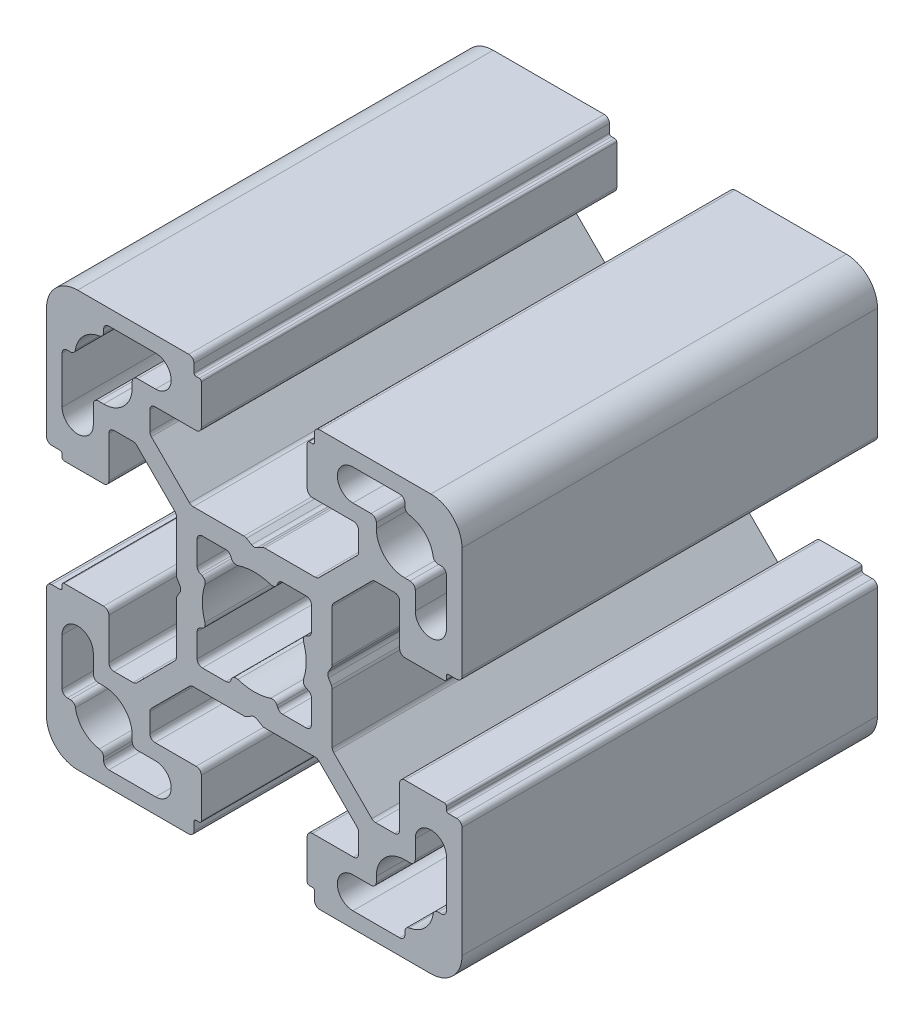
from build123d import *

# Parameters (mm, degrees)
EXTRUDE_1_DEPTH = 40


with BuildPart() as part:
    # Эскиз1 → Бобышка-Вытянуть1 (new body)
    with BuildSketch(Plane.XY):
        with BuildLine():
            Line((-18.5, -5.6), (-18.5, -5.3))
            ThreePointArc((-18.5, -5.3), (-18.441421356, -5.158578644), (-18.3, -5.1))
            Line((-18.3, -5.1), (-14.5, -5.1))
            ThreePointArc((-14.5, -5.1), (-14.146446609, -5.246446609), (-14, -5.6))
            Line((-14, -5.6), (-14, -9.55))
            ThreePointArc((-14, -9.55), (-13.853553391, -9.903553391), (-13.5, -10.05))
            Line((-13.5, -10.05), (-11.671320344, -10.05))
            ThreePointArc((-11.671320344, -10.05), (-11.479978627, -10.011939766), (-11.317766953, -9.903553391))
            Line((-11.317766953, -9.903553391), (-7.646446609, -6.232233047))
            ThreePointArc((-7.646446609, -6.232233047), (-7.538060234, -6.070021373), (-7.5, -5.878679656))
            Line((-7.5, -5.878679656), (-7.5, -1))
            ThreePointArc((-7.5, -1), (-7.482962913, -0.870590477), (-7.433012702, -0.75))
            Line((-7.433012702, -0.75), (-7.144337567, -0.25))
            ThreePointArc((-7.144337567, -0.25), (-7.077350269, 0), (-7.144337567, 0.25))
            Line((-7.144337567, 0.25), (-7.433012702, 0.75))
            ThreePointArc((-7.433012702, 0.75), (-7.482962913, 0.870590477), (-7.5, 1))
            Line((-7.5, 1), (-7.5, 5.878679656))
            ThreePointArc((-7.5, 5.878679656), (-7.538060234, 6.070021373), (-7.646446609, 6.232233047))
            Line((-7.646446609, 6.232233047), (-11.317766953, 9.903553391))
            ThreePointArc((-11.317766953, 9.903553391), (-11.479978627, 10.011939766), (-11.671320344, 10.05))
            Line((-11.671320344, 10.05), (-13.5, 10.05))
            ThreePointArc((-13.5, 10.05), (-13.853553391, 9.903553391), (-14, 9.55))
            Line((-14, 9.55), (-14, 5.6))
            ThreePointArc((-14, 5.6), (-14.146446609, 5.246446609), (-14.5, 5.1))
            Line((-14.5, 5.1), (-18.3, 5.1))
            ThreePointArc((-18.3, 5.1), (-18.441421356, 5.158578644), (-18.5, 5.3))
            Line((-18.5, 5.3), (-18.5, 5.6))
            ThreePointArc((-18.5, 5.6), (-18.558578644, 5.741421356), (-18.7, 5.8))
            Line((-18.7, 5.8), (-19.5, 5.8))
            ThreePointArc((-19.5, 5.8), (-19.853553391, 5.946446609), (-20, 6.3))
            Line((-20, 6.3), (-20, 17))
            ThreePointArc((-20, 17), (-19.121320344, 19.121320344), (-17, 20))
            Line((-17, 20), (-6.3, 20))
            ThreePointArc((-6.3, 20), (-5.946446609, 19.853553391), (-5.8, 19.5))
            Line((-5.8, 19.5), (-5.8, 18.7))
            ThreePointArc((-5.8, 18.7), (-5.741421356, 18.558578644), (-5.6, 18.5))
            Line((-5.6, 18.5), (-5.3, 18.5))
            ThreePointArc((-5.3, 18.5), (-5.158578644, 18.441421356), (-5.1, 18.3))
            Line((-5.1, 18.3), (-5.1, 14.5))
            ThreePointArc((-5.1, 14.5), (-5.246446609, 14.146446609), (-5.6, 14))
            Line((-5.6, 14), (-9.55, 14))
            ThreePointArc((-9.55, 14), (-9.903553391, 13.853553391), (-10.05, 13.5))
            Line((-10.05, 13.5), (-10.05, 11.671320344))
            ThreePointArc((-10.05, 11.671320344), (-10.011939766, 11.479978627), (-9.903553391, 11.317766953))
            Line((-9.903553391, 11.317766953), (-6.232233047, 7.646446609))
            ThreePointArc((-6.232233047, 7.646446609), (-6.070021373, 7.538060234), (-5.878679656, 7.5))
            Line((-5.878679656, 7.5), (-1, 7.5))
            ThreePointArc((-1, 7.5), (-0.870590477, 7.482962913), (-0.75, 7.433012702))
            Line((-0.75, 7.433012702), (-0.25, 7.144337567))
            ThreePointArc((-0.25, 7.144337567), (0, 7.077350269), (0.25, 7.144337567))
            Line((0.25, 7.144337567), (0.75, 7.433012702))
            ThreePointArc((0.75, 7.433012702), (0.870590477, 7.482962913), (1, 7.5))
            Line((1, 7.5), (5.878679656, 7.5))
            ThreePointArc((5.878679656, 7.5), (6.070021373, 7.538060234), (6.232233047, 7.646446609))
            Line((6.232233047, 7.646446609), (9.903553391, 11.317766953))
            ThreePointArc((9.903553391, 11.317766953), (10.011939766, 11.479978627), (10.05, 11.671320344))
            Line((10.05, 11.671320344), (10.05, 13.5))
            ThreePointArc((10.05, 13.5), (9.903553391, 13.853553391), (9.55, 14))
            Line((9.55, 14), (5.6, 14))
            ThreePointArc((5.6, 14), (5.246446609, 14.146446609), (5.1, 14.5))
            Line((5.1, 14.5), (5.1, 18.3))
            ThreePointArc((5.1, 18.3), (5.158578644, 18.441421356), (5.3, 18.5))
            Line((5.3, 18.5), (5.6, 18.5))
            ThreePointArc((5.6, 18.5), (5.741421356, 18.558578644), (5.8, 18.7))
            Line((5.8, 18.7), (5.8, 19.5))
            ThreePointArc((5.8, 19.5), (5.946446609, 19.853553391), (6.3, 20))
            Line((6.3, 20), (17, 20))
            ThreePointArc((17, 20), (19.121320344, 19.121320344), (20, 17))
            Line((20, 17), (20, 6.3))
            ThreePointArc((20, 6.3), (19.853553391, 5.946446609), (19.5, 5.8))
            Line((19.5, 5.8), (18.7, 5.8))
            ThreePointArc((18.7, 5.8), (18.558578644, 5.741421356), (18.5, 5.6))
            Line((18.5, 5.6), (18.5, 5.3))
            ThreePointArc((18.5, 5.3), (18.441421356, 5.158578644), (18.3, 5.1))
            Line((18.3, 5.1), (14.5, 5.1))
            ThreePointArc((14.5, 5.1), (14.146446609, 5.246446609), (14, 5.6))
            Line((14, 5.6), (14, 9.55))
            ThreePointArc((14, 9.55), (13.853553391, 9.903553391), (13.5, 10.05))
            Line((13.5, 10.05), (11.671320344, 10.05))
            ThreePointArc((11.671320344, 10.05), (11.479978627, 10.011939766), (11.317766953, 9.903553391))
            Line((11.317766953, 9.903553391), (7.646446609, 6.232233047))
            ThreePointArc((7.646446609, 6.232233047), (7.538060234, 6.070021373), (7.5, 5.878679656))
            Line((7.5, 5.878679656), (7.5, 1))
            ThreePointArc((7.5, 1), (7.482962913, 0.870590477), (7.433012702, 0.75))
            Line((7.433012702, 0.75), (7.144337567, 0.25))
            ThreePointArc((7.144337567, 0.25), (7.077350269, 0), (7.144337567, -0.25))
            Line((7.144337567, -0.25), (7.433012702, -0.75))
            ThreePointArc((7.433012702, -0.75), (7.482962913, -0.870590477), (7.5, -1))
            Line((7.5, -1), (7.5, -5.878679656))
            ThreePointArc((7.5, -5.878679656), (7.538060234, -6.070021373), (7.646446609, -6.232233047))
            Line((7.646446609, -6.232233047), (11.317766953, -9.903553391))
            ThreePointArc((11.317766953, -9.903553391), (11.479978627, -10.011939766), (11.671320344, -10.05))
            Line((11.671320344, -10.05), (13.5, -10.05))
            ThreePointArc((13.5, -10.05), (13.853553391, -9.903553391), (14, -9.55))
            Line((14, -9.55), (14, -5.6))
            ThreePointArc((14, -5.6), (14.146446609, -5.246446609), (14.5, -5.1))
            Line((14.5, -5.1), (18.3, -5.1))
            ThreePointArc((18.3, -5.1), (18.441421356, -5.158578644), (18.5, -5.3))
            Line((18.5, -5.3), (18.5, -5.6))
            ThreePointArc((18.5, -5.6), (18.558578644, -5.741421356), (18.7, -5.8))
            Line((18.7, -5.8), (19.5, -5.8))
            ThreePointArc((19.5, -5.8), (19.853553391, -5.946446609), (20, -6.3))
            Line((20, -6.3), (20, -17))
            ThreePointArc((20, -17), (19.121320344, -19.121320344), (17, -20))
            Line((17, -20), (6.3, -20))
            ThreePointArc((6.3, -20), (5.946446609, -19.853553391), (5.8, -19.5))
            Line((5.8, -19.5), (5.8, -18.7))
            ThreePointArc((5.8, -18.7), (5.741421356, -18.558578644), (5.6, -18.5))
            Line((5.6, -18.5), (5.3, -18.5))
            ThreePointArc((5.3, -18.5), (5.158578644, -18.441421356), (5.1, -18.3))
            Line((5.1, -18.3), (5.1, -14.5))
            ThreePointArc((5.1, -14.5), (5.246446609, -14.146446609), (5.6, -14))
            Line((5.6, -14), (9.55, -14))
            ThreePointArc((9.55, -14), (9.903553391, -13.853553391), (10.05, -13.5))
            Line((10.05, -13.5), (10.05, -11.671320344))
            ThreePointArc((10.05, -11.671320344), (10.011939766, -11.479978627), (9.903553391, -11.317766953))
            Line((9.903553391, -11.317766953), (6.232233047, -7.646446609))
            ThreePointArc((6.232233047, -7.646446609), (6.070021373, -7.538060234), (5.878679656, -7.5))
            Line((5.878679656, -7.5), (1, -7.5))
            ThreePointArc((1, -7.5), (0.870590477, -7.482962913), (0.75, -7.433012702))
            Line((0.75, -7.433012702), (0.25, -7.144337567))
            ThreePointArc((0.25, -7.144337567), (0, -7.077350269), (-0.25, -7.144337567))
            Line((-0.25, -7.144337567), (-0.75, -7.433012702))
            ThreePointArc((-0.75, -7.433012702), (-0.870590477, -7.482962913), (-1, -7.5))
            Line((-1, -7.5), (-5.878679656, -7.5))
            ThreePointArc((-5.878679656, -7.5), (-6.070021373, -7.538060234), (-6.232233047, -7.646446609))
            Line((-6.232233047, -7.646446609), (-9.903553391, -11.317766953))
            ThreePointArc((-9.903553391, -11.317766953), (-10.011939766, -11.479978627), (-10.05, -11.671320344))
            Line((-10.05, -11.671320344), (-10.05, -13.5))
            ThreePointArc((-10.05, -13.5), (-9.903553391, -13.853553391), (-9.55, -14))
            Line((-9.55, -14), (-5.6, -14))
            ThreePointArc((-5.6, -14), (-5.246446609, -14.146446609), (-5.1, -14.5))
            Line((-5.1, -14.5), (-5.1, -18.3))
            ThreePointArc((-5.1, -18.3), (-5.158578644, -18.441421356), (-5.3, -18.5))
            Line((-5.3, -18.5), (-5.6, -18.5))
            ThreePointArc((-5.6, -18.5), (-5.741421356, -18.558578644), (-5.8, -18.7))
            Line((-5.8, -18.7), (-5.8, -19.5))
            ThreePointArc((-5.8, -19.5), (-5.946446609, -19.853553391), (-6.3, -20))
            Line((-6.3, -20), (-17, -20))
            ThreePointArc((-17, -20), (-19.121320344, -19.121320344), (-20, -17))
            Line((-20, -17), (-20, -6.3))
            ThreePointArc((-20, -6.3), (-19.853553391, -5.946446609), (-19.5, -5.8))
            Line((-19.5, -5.8), (-18.7, -5.8))
            ThreePointArc((-18.7, -5.8), (-18.558578644, -5.741421356), (-18.5, -5.6))
        make_face()
        with BuildLine():
            Line((-14.5, 18), (-14.5, 17.711308145))
            ThreePointArc((-14.5, 17.711308145), (-14.620222737, 17.386086327), (-14.923076923, 17.217260738))
            ThreePointArc((-14.923076923, 17.217260738), (-16.444543648, 16.444543648), (-17.217260738, 14.923076923))
            ThreePointArc((-17.217260738, 14.923076923), (-17.386086327, 14.620222737), (-17.711308145, 14.5))
            Line((-17.711308145, 14.5), (-18, 14.5))
            ThreePointArc((-18, 14.5), (-18.353553391, 14.353553391), (-18.5, 14))
            Line((-18.5, 14), (-18.5, 9.5))
            ThreePointArc((-18.5, 9.5), (-17, 8), (-15.5, 9.5))
            Line((-15.5, 9.5), (-15.5, 11.25))
            ThreePointArc((-15.5, 11.25), (-15.353553391, 11.603553391), (-15, 11.75))
            Line((-15, 11.75), (-14.5, 11.75))
            ThreePointArc((-14.5, 11.75), (-12.555456352, 12.555456352), (-11.75, 14.5))
            Line((-11.75, 14.5), (-11.75, 15))
            ThreePointArc((-11.75, 15), (-11.603553391, 15.353553391), (-11.25, 15.5))
            Line((-11.25, 15.5), (-9.5, 15.5))
            ThreePointArc((-9.5, 15.5), (-8, 17), (-9.5, 18.5))
            Line((-9.5, 18.5), (-14, 18.5))
            ThreePointArc((-14, 18.5), (-14.353553391, 18.353553391), (-14.5, 18))
        make_face(mode=Mode.SUBTRACT)
        with BuildLine():
            Line((-5.199374534, 2.269284327), (-5.020474811, 2.191496514))
            ThreePointArc((-5.020474811, 2.191496514), (-4.763314859, 1.936869058), (-4.745317587, 1.57542407))
            ThreePointArc((-4.745317587, 1.57542407), (-5, 0), (-4.745317587, -1.57542407))
            ThreePointArc((-4.745317587, -1.57542407), (-4.763314859, -1.936869058), (-5.020474811, -2.191496514))
            Line((-5.020474811, -2.191496514), (-5.199374534, -2.269284327))
            ThreePointArc((-5.199374534, -2.269284327), (-5.418143078, -2.45366775), (-5.5, -2.727814365))
            Line((-5.5, -2.727814365), (-5.5, -5))
            ThreePointArc((-5.5, -5), (-5.353553391, -5.353553391), (-5, -5.5))
            Line((-5, -5.5), (-2.727814365, -5.5))
            ThreePointArc((-2.727814365, -5.5), (-2.45366775, -5.418143078), (-2.269284327, -5.199374534))
            Line((-2.269284327, -5.199374534), (-2.191496514, -5.020474811))
            ThreePointArc((-2.191496514, -5.020474811), (-1.936869058, -4.763314859), (-1.57542407, -4.745317587))
            ThreePointArc((-1.57542407, -4.745317587), (0, -5), (1.57542407, -4.745317587))
            ThreePointArc((1.57542407, -4.745317587), (1.936869058, -4.763314859), (2.191496514, -5.020474811))
            Line((2.191496514, -5.020474811), (2.269284327, -5.199374534))
            ThreePointArc((2.269284327, -5.199374534), (2.45366775, -5.418143078), (2.727814365, -5.5))
            Line((2.727814365, -5.5), (5, -5.5))
            ThreePointArc((5, -5.5), (5.353553391, -5.353553391), (5.5, -5))
            Line((5.5, -5), (5.5, -2.727814365))
            ThreePointArc((5.5, -2.727814365), (5.418143078, -2.45366775), (5.199374534, -2.269284327))
            Line((5.199374534, -2.269284327), (5.020474811, -2.191496514))
            ThreePointArc((5.020474811, -2.191496514), (4.763314859, -1.936869058), (4.745317587, -1.57542407))
            ThreePointArc((4.745317587, -1.57542407), (5, 0), (4.745317587, 1.57542407))
            ThreePointArc((4.745317587, 1.57542407), (4.763314859, 1.936869058), (5.020474811, 2.191496514))
            Line((5.020474811, 2.191496514), (5.199374534, 2.269284327))
            ThreePointArc((5.199374534, 2.269284327), (5.418143078, 2.45366775), (5.5, 2.727814365))
            Line((5.5, 2.727814365), (5.5, 5))
            ThreePointArc((5.5, 5), (5.353553391, 5.353553391), (5, 5.5))
            Line((5, 5.5), (2.727814365, 5.5))
            ThreePointArc((2.727814365, 5.5), (2.45366775, 5.418143078), (2.269284327, 5.199374534))
            Line((2.269284327, 5.199374534), (2.191496514, 5.020474811))
            ThreePointArc((2.191496514, 5.020474811), (1.936869058, 4.763314859), (1.57542407, 4.745317587))
            ThreePointArc((1.57542407, 4.745317587), (0, 5), (-1.57542407, 4.745317587))
            ThreePointArc((-1.57542407, 4.745317587), (-1.936869058, 4.763314859), (-2.191496514, 5.020474811))
            Line((-2.191496514, 5.020474811), (-2.269284327, 5.199374534))
            ThreePointArc((-2.269284327, 5.199374534), (-2.45366775, 5.418143078), (-2.727814365, 5.5))
            Line((-2.727814365, 5.5), (-5, 5.5))
            ThreePointArc((-5, 5.5), (-5.353553391, 5.353553391), (-5.5, 5))
            Line((-5.5, 5), (-5.5, 2.727814365))
            ThreePointArc((-5.5, 2.727814365), (-5.418143078, 2.45366775), (-5.199374534, 2.269284327))
        make_face(mode=Mode.SUBTRACT)
        with BuildLine():
            Line((15.5, 9.5), (15.5, 11.25))
            ThreePointArc((15.5, 11.25), (15.353553391, 11.603553391), (15, 11.75))
            Line((15, 11.75), (14.5, 11.75))
            ThreePointArc((14.5, 11.75), (12.555456352, 12.555456352), (11.75, 14.5))
            Line((11.75, 14.5), (11.75, 15))
            ThreePointArc((11.75, 15), (11.603553391, 15.353553391), (11.25, 15.5))
            Line((11.25, 15.5), (9.5, 15.5))
            ThreePointArc((9.5, 15.5), (8, 17), (9.5, 18.5))
            Line((9.5, 18.5), (14, 18.5))
            ThreePointArc((14, 18.5), (14.353553391, 18.353553391), (14.5, 18))
            Line((14.5, 18), (14.5, 17.711308145))
            ThreePointArc((14.5, 17.711308145), (14.620222737, 17.386086327), (14.923076923, 17.217260738))
            ThreePointArc((14.923076923, 17.217260738), (16.444543648, 16.444543648), (17.217260738, 14.923076923))
            ThreePointArc((17.217260738, 14.923076923), (17.386086327, 14.620222737), (17.711308145, 14.5))
            Line((17.711308145, 14.5), (18, 14.5))
            ThreePointArc((18, 14.5), (18.353553391, 14.353553391), (18.5, 14))
            Line((18.5, 14), (18.5, 9.5))
            ThreePointArc((18.5, 9.5), (17, 8), (15.5, 9.5))
        make_face(mode=Mode.SUBTRACT)
        with BuildLine():
            Line((14.5, -18), (14.5, -17.711308145))
            ThreePointArc((14.5, -17.711308145), (14.620222737, -17.386086327), (14.923076923, -17.217260738))
            ThreePointArc((14.923076923, -17.217260738), (16.444543648, -16.444543648), (17.217260738, -14.923076923))
            ThreePointArc((17.217260738, -14.923076923), (17.386086327, -14.620222737), (17.711308145, -14.5))
            Line((17.711308145, -14.5), (18, -14.5))
            ThreePointArc((18, -14.5), (18.353553391, -14.353553391), (18.5, -14))
            Line((18.5, -14), (18.5, -9.5))
            ThreePointArc((18.5, -9.5), (17, -8), (15.5, -9.5))
            Line((15.5, -9.5), (15.5, -11.25))
            ThreePointArc((15.5, -11.25), (15.353553391, -11.603553391), (15, -11.75))
            Line((15, -11.75), (14.5, -11.75))
            ThreePointArc((14.5, -11.75), (12.555456352, -12.555456352), (11.75, -14.5))
            Line((11.75, -14.5), (11.75, -15))
            ThreePointArc((11.75, -15), (11.603553391, -15.353553391), (11.25, -15.5))
            Line((11.25, -15.5), (9.5, -15.5))
            ThreePointArc((9.5, -15.5), (8, -17), (9.5, -18.5))
            Line((9.5, -18.5), (14, -18.5))
            ThreePointArc((14, -18.5), (14.353553391, -18.353553391), (14.5, -18))
        make_face(mode=Mode.SUBTRACT)
        with BuildLine():
            Line((-15.5, -9.5), (-15.5, -11.25))
            ThreePointArc((-15.5, -11.25), (-15.353553391, -11.603553391), (-15, -11.75))
            Line((-15, -11.75), (-14.5, -11.75))
            ThreePointArc((-14.5, -11.75), (-12.555456352, -12.555456352), (-11.75, -14.5))
            Line((-11.75, -14.5), (-11.75, -15))
            ThreePointArc((-11.75, -15), (-11.603553391, -15.353553391), (-11.25, -15.5))
            Line((-11.25, -15.5), (-9.5, -15.5))
            ThreePointArc((-9.5, -15.5), (-8, -17), (-9.5, -18.5))
            Line((-9.5, -18.5), (-14, -18.5))
            ThreePointArc((-14, -18.5), (-14.353553391, -18.353553391), (-14.5, -18))
            Line((-14.5, -18), (-14.5, -17.711308145))
            ThreePointArc((-14.5, -17.711308145), (-14.620222737, -17.386086327), (-14.923076923, -17.217260738))
            ThreePointArc((-14.923076923, -17.217260738), (-16.444543648, -16.444543648), (-17.217260738, -14.923076923))
            ThreePointArc((-17.217260738, -14.923076923), (-17.386086327, -14.620222737), (-17.711308145, -14.5))
            Line((-17.711308145, -14.5), (-18, -14.5))
            ThreePointArc((-18, -14.5), (-18.353553391, -14.353553391), (-18.5, -14))
            Line((-18.5, -14), (-18.5, -9.5))
            ThreePointArc((-18.5, -9.5), (-17, -8), (-15.5, -9.5))
        make_face(mode=Mode.SUBTRACT)
    extrude(amount=EXTRUDE_1_DEPTH)


solid = part.part
